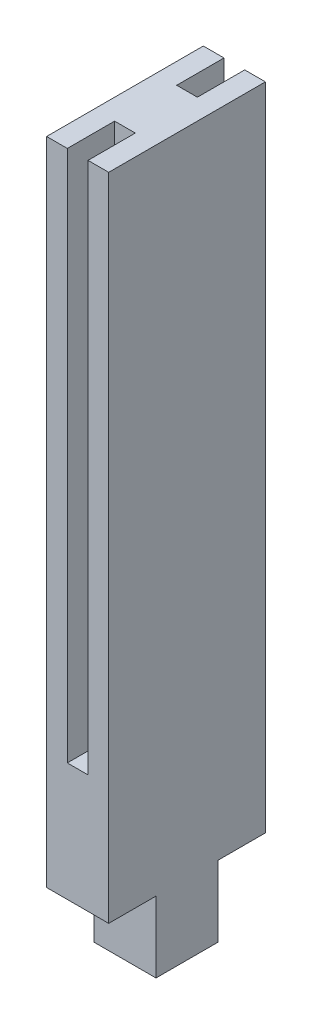
from build123d import *

# Parameters (mm, degrees)
SKETCH1_W           = 5.25
SKETCH1_H           = 5.25
BOSS_EXTRUDE1_DEPTH = 6
SKETCH2_W           = 5.25
SKETCH2_H           = 9.25
BOSS_EXTRUDE2_DEPTH = 55
SKETCH3_W           = 1.75
SKETCH3_H           = 8
CUT_EXTRUDE1_DEPTH  = 45
SKETCH4_W           = 5.25
SKETCH4_H           = 55
BOSS_EXTRUDE3_DEPTH = 4
SKETCH5_W           = 1.75
SKETCH5_H           = 8
CUT_EXTRUDE2_DEPTH  = 45


with BuildPart() as part:
    # Sketch1 → Boss-Extrude1 (new body)
    with BuildSketch(Plane(origin=(0, 0, 0), x_dir=(1, 0, 0), z_dir=(0, 1, 0))):
        Rectangle(SKETCH1_W, SKETCH1_H)
    extrude(amount=BOSS_EXTRUDE1_DEPTH)

    # Sketch2 → Boss-Extrude2 (add)
    with BuildSketch(Plane(origin=(0, 6, 0), x_dir=(1, 0, 0), z_dir=(0, 1, 0))):
        with Locations((0, -2)):
            Rectangle(SKETCH2_W, SKETCH2_H)
    extrude(amount=BOSS_EXTRUDE2_DEPTH)

    # Sketch3 → Cut-Extrude1 (cut)
    with BuildSketch(Plane(origin=(0, 61, 0), x_dir=(1, 0, 0), z_dir=(0, 1, 0))):
        with Locations((0, -6.625)):
            Rectangle(SKETCH3_W, SKETCH3_H)
    extrude(amount=-CUT_EXTRUDE1_DEPTH, mode=Mode.SUBTRACT)

    # Sketch4 → Boss-Extrude3 (add)
    with BuildSketch(Plane(origin=(0, 0, -2.625), x_dir=(-1, 0, 0), z_dir=(0, 0, -1))):
        with Locations((0, 33.5)):
            Rectangle(SKETCH4_W, SKETCH4_H)
    extrude(amount=BOSS_EXTRUDE3_DEPTH)

    # Sketch5 → Cut-Extrude2 (cut)
    with BuildSketch(Plane(origin=(0, 61, 0), x_dir=(1, 0, 0), z_dir=(0, 1, 0))):
        with Locations((0, 6.625)):
            Rectangle(SKETCH5_W, SKETCH5_H)
    extrude(amount=-CUT_EXTRUDE2_DEPTH, mode=Mode.SUBTRACT)


solid = part.part
